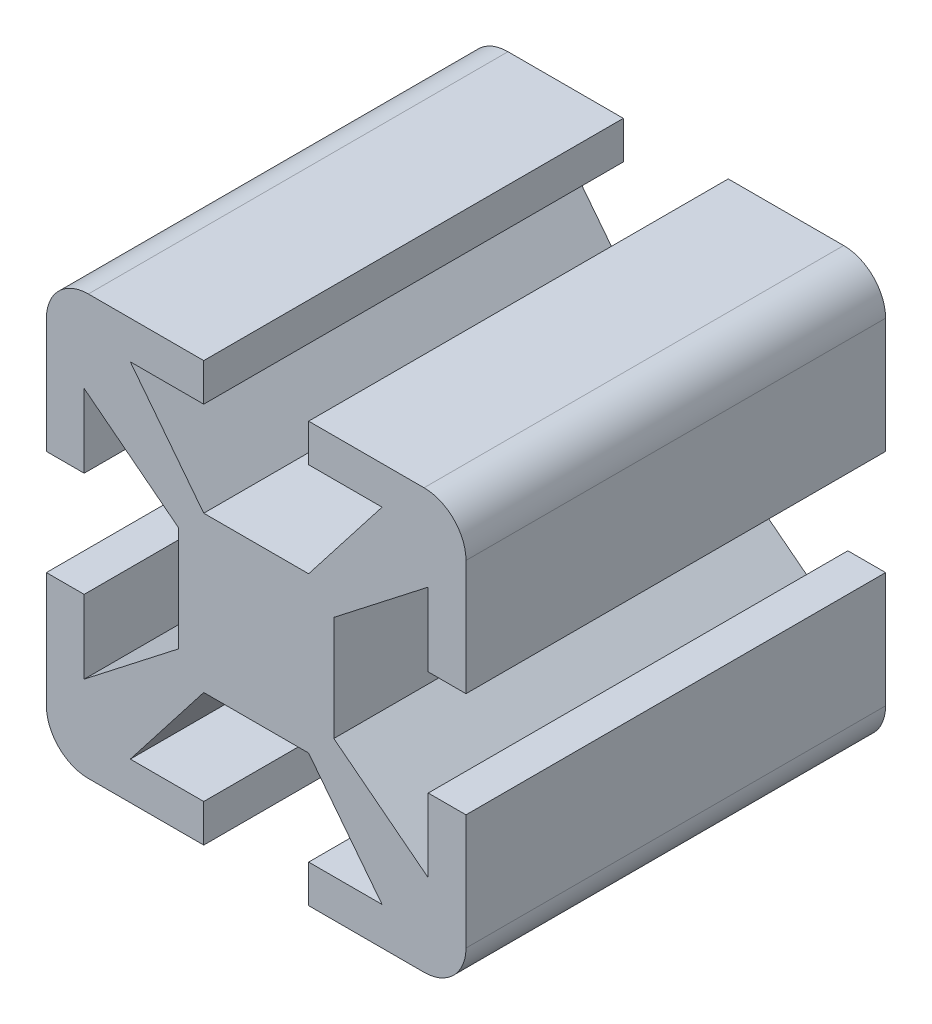
from build123d import *

# Parameters (mm, degrees)
EXTRUSION1_DEPTH        = 20
ENL_V_MAT_EXTRU_1_DEPTH = 300
ENL_V_MAT_EXTRU_3_DEPTH = 300
ENL_V_MAT_EXTRU_4_DEPTH = 21
ENL_V_MAT_EXTRU_7_DEPTH = 21


with BuildPart() as part:
    # Esquisse1 → Extrusion1 (new body)
    with BuildSketch(Plane.XY):
        with BuildLine():
            Line((-10, 8), (-10, -8))
            ThreePointArc((-10, -8), (-9.414213562, -9.414213562), (-8, -10))
            Line((-8, -10), (8, -10))
            ThreePointArc((8, -10), (9.414213562, -9.414213562), (10, -8))
            Line((10, -8), (10, 8))
            ThreePointArc((10, 8), (9.414213562, 9.414213562), (8, 10))
            Line((8, 10), (-8, 10))
            ThreePointArc((-8, 10), (-9.414213562, 9.414213562), (-10, 8))
        make_face()
    extrude(amount=EXTRUSION1_DEPTH)

    # Esquisse3 → Enlèv. mat.-Extru.1 (cut)
    with BuildSketch(Plane.XY.offset(20)):
        Polygon((10, 2.5), (8.2, 2.5), (8.2, 6), (3.7, 2.5), (3.7, -2.5), (8.2, -6), (8.2, -2.5), (10, -2.5), align=None)
    extrude(amount=-ENL_V_MAT_EXTRU_1_DEPTH, mode=Mode.SUBTRACT)

    # Esquisse5 → Enlèv. mat.-Extru.3 (cut)
    with BuildSketch(Plane.XY.offset(20)):
        Polygon((-2.5, 10), (-2.5, 8.2), (-6, 8.2), (-2.5, 3.7), (2.5, 3.7), (6, 8.2), (2.5, 8.2), (2.5, 10), align=None)
    extrude(amount=-ENL_V_MAT_EXTRU_3_DEPTH, mode=Mode.SUBTRACT)

    # Esquisse6 → Enlèv. mat.-Extru.4 (cut, through all)
    with BuildSketch(Plane.XY.offset(20)):
        Polygon((-2.5, -10), (-2.5, -8.2), (-6, -8.2), (-2.5, -3.7), (2.5, -3.7), (6, -8.2), (2.5, -8.2), (2.5, -10), align=None)
    extrude(amount=-ENL_V_MAT_EXTRU_4_DEPTH, mode=Mode.SUBTRACT)

    # Esquisse4 → Enlèv. mat.-Extru.7 (cut, through all)
    with BuildSketch(Plane.XY.offset(20)):
        Polygon((-10, 2.5), (-8.2, 2.5), (-8.2, 6), (-3.7, 2.5), (-3.7, -2.5), (-8.2, -6), (-8.2, -2.5), (-10, -2.5), align=None)
    extrude(amount=-ENL_V_MAT_EXTRU_7_DEPTH, mode=Mode.SUBTRACT)


solid = part.part
